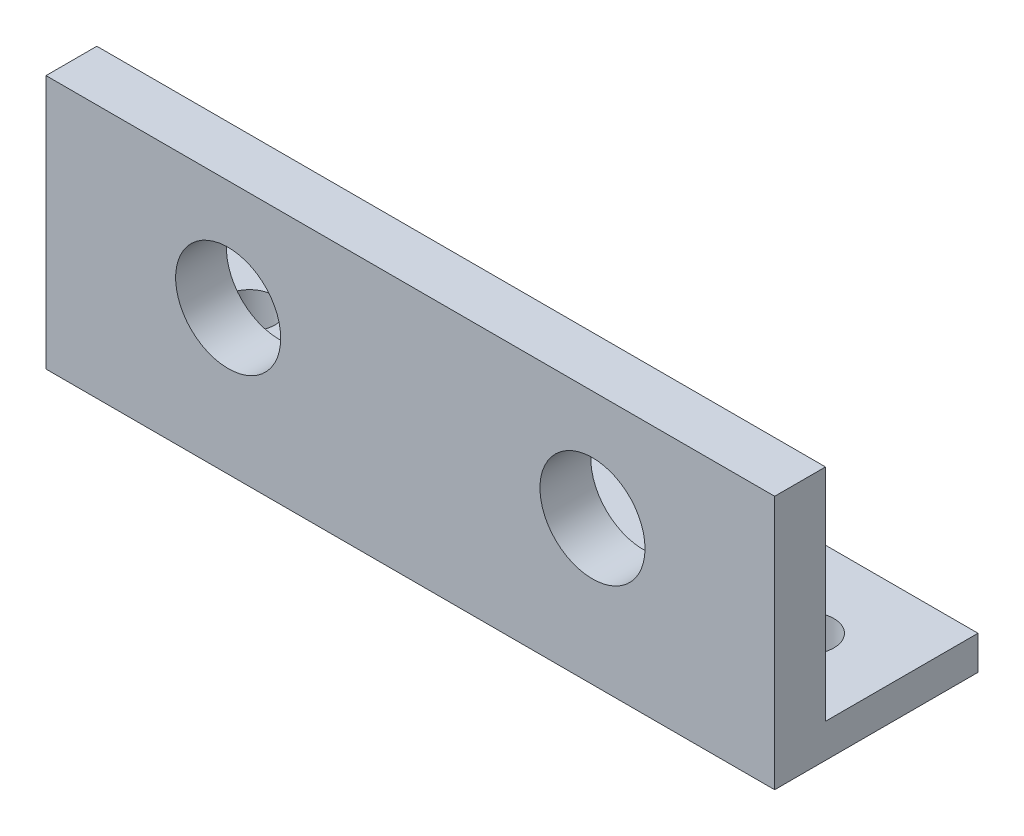
from build123d import *

# Parameters (mm, degrees)
SKETCH1_W           = 43
SKETCH1_H           = 12
SKETCH1_R           = 1.5
BOSS_EXTRUDE1_DEPTH = 2
SKETCH2_W           = 43
SKETCH2_H           = 3
BOSS_EXTRUDE2_DEPTH = 13
SKETCH3_R           = 3.1
CUT_EXTRUDE1_DEPTH  = 13


with BuildPart() as part:
    # Sketch1 → Boss-Extrude1 (new body)
    with BuildSketch(Plane(origin=(0, 0, 0), x_dir=(1, 0, 0), z_dir=(0, 1, 0))):
        with Locations((-16.5, -1)):
            Rectangle(SKETCH1_W, SKETCH1_H)
        with Locations((-33, 0)):
            Circle(SKETCH1_R, mode=Mode.SUBTRACT)
        Circle(SKETCH1_R, mode=Mode.SUBTRACT)
    extrude(amount=BOSS_EXTRUDE1_DEPTH)

    # Sketch2 → Boss-Extrude2 (add)
    with BuildSketch(Plane(origin=(0, 2, 0), x_dir=(1, 0, 0), z_dir=(0, 1, 0))):
        with Locations((-16.5, -5.5)):
            Rectangle(SKETCH2_W, SKETCH2_H)
    extrude(amount=BOSS_EXTRUDE2_DEPTH)

    # Sketch3 → Cut-Extrude1 (cut)
    with BuildSketch(Plane.XY.offset(7)):
        with Locations((-27.25, 8.5)):
            Circle(SKETCH3_R)
        with Locations((-5.75, 8.5)):
            Circle(SKETCH3_R)
    extrude(amount=-CUT_EXTRUDE1_DEPTH, mode=Mode.SUBTRACT)


solid = part.part
